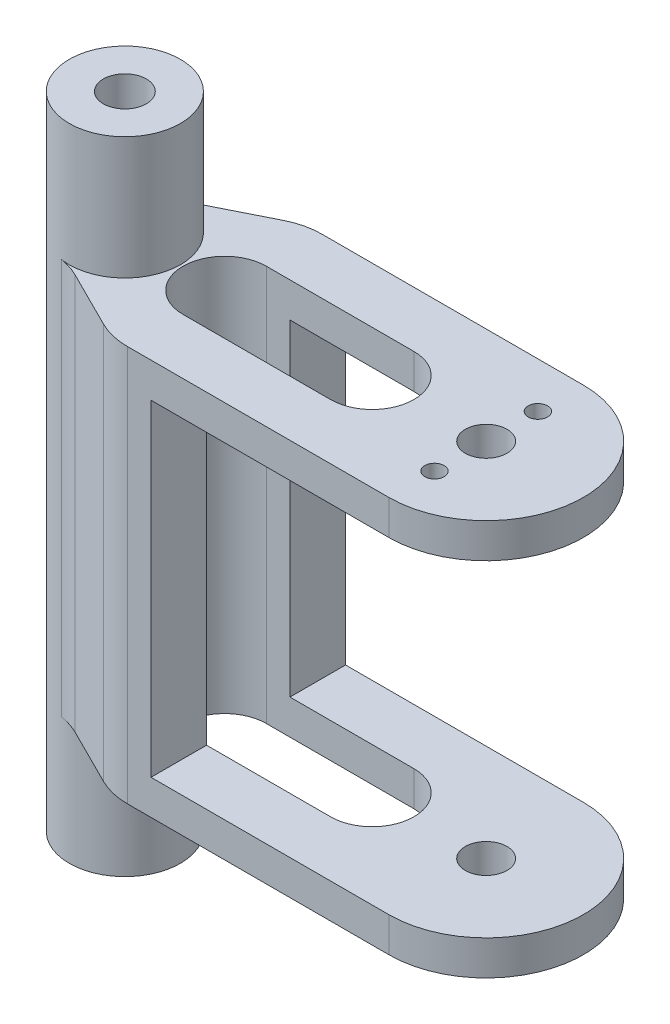
from build123d import *

# Parameters (mm, degrees)
SKETCH1_R                = 3
BOSS_EXTRUDE4_DEPTH      = 5
SKETCH4_W                = 5.761442696
SKETCH4_H                = 28
BOSS_EXTRUDE5_DEPTH      = 47
SKETCH6_W                = 5.761442696
SKETCH6_H                = 28
SKETCH6_R                = 14
SKETCH6_R_2              = 3
BOSS_EXTRUDE6_DEPTH      = 5
SKETCH8_R                = 8
SKETCH8_R_2              = 3.1
BOSS_EXTRUDE7_DEPTH      = 17.61
BOSS_EXTRUDE7_DEPTH_BACK = 74.61
BOSS_EXTRUDE8_DEPTH      = 57
FILLET1_R                = 10
FILLET2_R                = 10
CUT_EXTRUDE1_DEPTH       = 57
SKETCH14_R               = 1.395
CUT_EXTRUDE2_DEPTH       = 3


with BuildPart() as part:
    # Sketch1 → Boss-Extrude4 (new body)
    with BuildSketch(Plane(origin=(0, 0, 0), x_dir=(1, 0, 0), z_dir=(0, 1, 0))):
        with BuildLine():
            Line((-62.942048288, -14), (-22.942048288, -14))
            ThreePointArc((-22.942048288, -14), (-8.942048288, 0), (-22.942048288, 14))
            Line((-22.942048288, 14), (-62.942048288, 14))
            Line((-62.942048288, 14), (-62.942048288, -14))
        make_face()
        with Locations((-22.942048288, 0)):
            Circle(SKETCH1_R, mode=Mode.SUBTRACT)
    extrude(amount=BOSS_EXTRUDE4_DEPTH)

    # Sketch4 → Boss-Extrude5 (add)
    with BuildSketch(Plane(origin=(0, 5, 0), x_dir=(1, 0, 0), z_dir=(0, 1, 0))):
        with Locations((-60.06132694, 0)):
            Rectangle(SKETCH4_W, SKETCH4_H)
    extrude(amount=BOSS_EXTRUDE5_DEPTH)

    # Sketch6 → Boss-Extrude6 (add)
    with BuildSketch(Plane(origin=(0, 52, 0), x_dir=(1, 0, 0), z_dir=(0, 1, 0))):
        with BuildLine():
            ThreePointArc((-22.942048288, -14), (-36.942048288, 0), (-22.942048288, 14))
            Line((-22.942048288, 14), (-57.180605592, 14))
            Line((-57.180605592, 14), (-57.180605592, -14))
            Line((-57.180605592, -14), (-22.942048288, -14))
        make_face()
        with Locations((-60.06132694, 0)):
            Rectangle(SKETCH6_W, SKETCH6_H)
        with Locations((-22.942048288, 0)):
            Circle(SKETCH6_R)
        with Locations((-22.942048288, 0)):
            Circle(SKETCH6_R_2, mode=Mode.SUBTRACT)
    extrude(amount=BOSS_EXTRUDE6_DEPTH)



with BuildPart() as body_2:
    # Sketch8 → Boss-Extrude7 (new body, two sides)
    with BuildSketch(Plane(origin=(0, 57, 0), x_dir=(1, 0, 0), z_dir=(0, 1, 0))) as boss_extrude7_sk:
        with Locations((-74.942048288, 0)):
            Circle(SKETCH8_R)
        with Locations((-74.942048288, 0)):
            Circle(SKETCH8_R_2, mode=Mode.SUBTRACT)
    extrude(amount=BOSS_EXTRUDE7_DEPTH)
    extrude(boss_extrude7_sk.sketch, amount=-BOSS_EXTRUDE7_DEPTH_BACK)


with BuildPart() as part_1:
    add(part.part)

    add(body_2.part)  # Boss-Extrude8 merges body 2
    # Sketch11 → Boss-Extrude8 (add)
    with BuildSketch(Plane.XZ):
        with BuildLine():
            Line((-62.942048288, 14), (-74.942048288, 8))
            ThreePointArc((-74.942048288, 8), (-69.285194038, 5.656854249), (-66.942048288, 0))
            ThreePointArc((-66.942048288, 0), (-69.285194038, -5.656854249), (-74.942048288, -8))
            Line((-74.942048288, -8), (-62.942048288, -14))
            Line((-62.942048288, -14), (-62.942048288, 14))
        make_face()
    extrude(amount=-BOSS_EXTRUDE8_DEPTH)

    # Fillet1
    fillet1_edges = [part_1.edges().sort_by_distance(p)[0] for p in [
        (-62.942048288, 28.5, 14),
        (-62.942048288, 28.5, -14),
    ]]
    fillet(fillet1_edges, radius=FILLET1_R)

    # Fillet2
    fillet2_edges = [part_1.edges().sort_by_distance(p)[0] for p in [
        (-74.942048288, 28.5, 8),
        (-74.942048288, 28.5, -8),
    ]]
    fillet(fillet2_edges, radius=FILLET2_R)

    # Sketch13 → Cut-Extrude1 (cut)
    with BuildSketch(Plane.XZ):
        with BuildLine():
            Line((-60.581368513, 6), (-39.338409666, 6))
            ThreePointArc((-39.338409666, 6), (-33.338409666, 0), (-39.338409666, -6))
            Line((-39.338409666, -6), (-60.581368513, -6))
            ThreePointArc((-60.581368513, -6), (-66.581368513, 0), (-60.581368513, 6))
        make_face()
    extrude(amount=-CUT_EXTRUDE1_DEPTH, mode=Mode.SUBTRACT)

    # Sketch14 → Cut-Extrude2 (cut)
    with BuildSketch(Plane(origin=(0, 57, 0), x_dir=(1, 0, 0), z_dir=(0, 1, 0))):
        with Locations((-22.942048288, 7.4422)):
            Circle(SKETCH14_R)
        with Locations((-22.942048288, -7.4422)):
            Circle(SKETCH14_R)
    extrude(amount=-CUT_EXTRUDE2_DEPTH, mode=Mode.SUBTRACT)


solid = part_1.part
